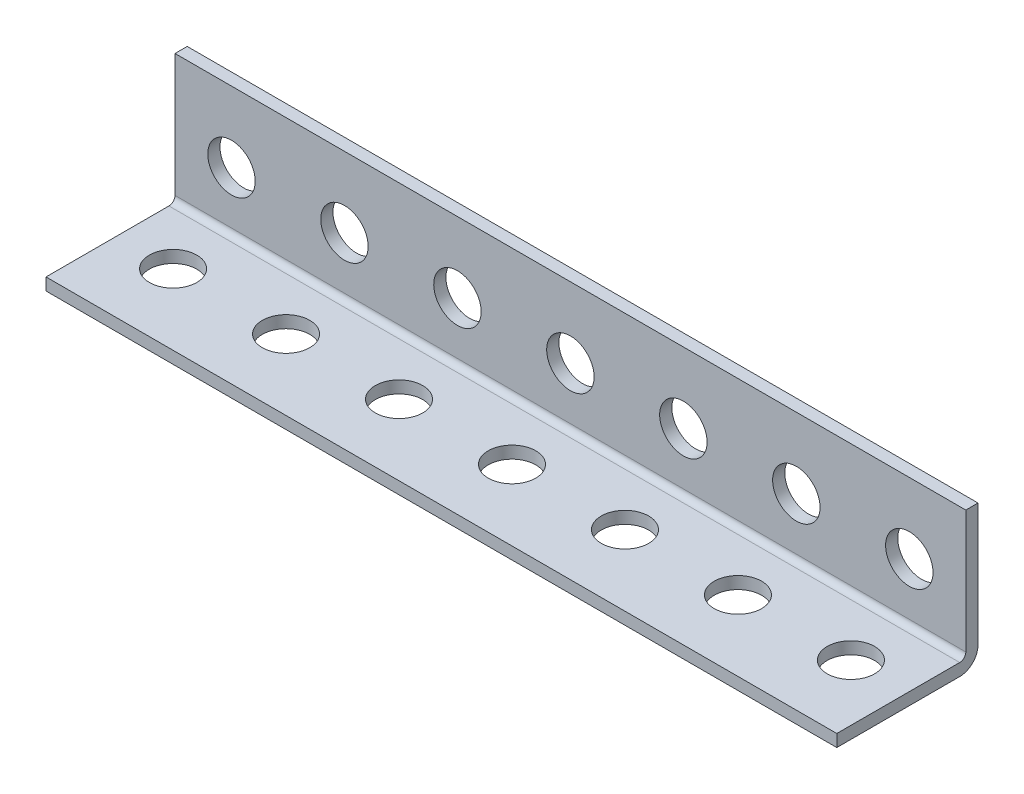
from build123d import *

# Parameters (mm, degrees)
BOSS_EXTRUDE1_DEPTH      = 609.6
BOSS_EXTRUDE1_DEPTH_BACK = 609.6
SKETCH5_R                = 5.334
CUT_EXTRUDE1_DEPTH       = 16.875
SKETCH6_R                = 5.334
CUT_EXTRUDE2_DEPTH       = 16.875
LPATTERN1_COUNT          = 48
LPATTERN1_PITCH          = 25.4
SKETCH7_W                = 635
SKETCH7_H                = 31.75
CUT_EXTRUDE3_DEPTH       = 70
SKETCH8_R                = 5.334
SKETCH8_W                = 25.4
SKETCH8_H                = 4.1148
CUT_EXTRUDE4_DEPTH       = 70
SKETCH9_R                = 5.334
SKETCH9_W                = 381
SKETCH9_H                = 4.1148
CUT_EXTRUDE5_DEPTH       = 70


with BuildPart() as part:
    # Sketch4 → Boss-Extrude1 (new body, two sides)
    with BuildSketch(Plane(origin=(0, 0, 0), x_dir=(0, 0, -1), z_dir=(1, 0, 0))) as boss_extrude1_sk:
        with BuildLine():
            Line((-15.875, -13.1318), (11.7602, -13.1318))
            ThreePointArc((11.7602, -13.1318), (12.730067661, -12.730067661), (13.1318, -11.7602))
            Line((13.1318, -11.7602), (13.1318, 15.875))
            Line((13.1318, 15.875), (15.875, 15.875))
            Line((15.875, 15.875), (15.875, -11.7602))
            ThreePointArc((15.875, -11.7602), (14.669802983, -14.669802983), (11.7602, -15.875))
            Line((11.7602, -15.875), (-15.875, -15.875))
            Line((-15.875, -15.875), (-15.875, -13.1318))
        make_face()
    extrude(amount=BOSS_EXTRUDE1_DEPTH)
    extrude(boss_extrude1_sk.sketch, amount=-BOSS_EXTRUDE1_DEPTH_BACK)

    # Sketch5 → Cut-Extrude1 (cut, through all)
    with BuildSketch(Plane.XY):
        with Locations((596.9, 0)):
            Circle(SKETCH5_R)
    cut_extrude1 = extrude(amount=-CUT_EXTRUDE1_DEPTH, mode=Mode.SUBTRACT)

    # Sketch6 → Cut-Extrude2 (cut, through all)
    with BuildSketch(Plane(origin=(0, 0, 0), x_dir=(1, 0, 0), z_dir=(0, 1, 0))):
        with Locations((596.9, 0)):
            Circle(SKETCH6_R)
    cut_extrude2 = extrude(amount=-CUT_EXTRUDE2_DEPTH, mode=Mode.SUBTRACT)

    # LPattern1: Cut-Extrude1, Cut-Extrude2 ×48
    with Locations(*[(-i * LPATTERN1_PITCH, 0, 0) for i in range(1, LPATTERN1_COUNT)]):
        add(cut_extrude1, mode=Mode.SUBTRACT)
        add(cut_extrude2, mode=Mode.SUBTRACT)

    # Sketch7 → Cut-Extrude3 (cut)
    with BuildSketch(Plane(origin=(0, 0, -15.875), x_dir=(-1, 0, 0), z_dir=(0, 0, -1))):
        with Locations((-292.1, 0)):
            Rectangle(SKETCH7_W, SKETCH7_H)
    extrude(amount=-CUT_EXTRUDE3_DEPTH, mode=Mode.SUBTRACT)

    # Sketch8 → Cut-Extrude4 (cut)
    with BuildSketch(Plane(origin=(0, 0, -15.875), x_dir=(-1, 0, 0), z_dir=(0, 0, -1))):
        Polygon((50.8, 15.875), (25.4, 15.875), (25.4, -11.7602), (50.8, -11.7602), (50.8, 0), align=None)
        with Locations((38.1, 0)):
            Circle(SKETCH8_R, mode=Mode.SUBTRACT)
        with Locations((38.1, -13.8176)):
            Rectangle(SKETCH8_W, SKETCH8_H)
    extrude(amount=-CUT_EXTRUDE4_DEPTH, mode=Mode.SUBTRACT)

    # Sketch9 → Cut-Extrude5 (cut)
    with BuildSketch(Plane(origin=(0, 0, -15.875), x_dir=(-1, 0, 0), z_dir=(0, 0, -1))):
        Polygon((431.8, 15.875), (50.8, 15.875), (50.8, -11.7602), (431.8, -11.7602), (431.8, 0), align=None)
        with Locations((63.5, 0)):
            Circle(SKETCH9_R, mode=Mode.SUBTRACT)
        with Locations((88.9, 0)):
            Circle(SKETCH9_R, mode=Mode.SUBTRACT)
        with Locations((114.3, 0)):
            Circle(SKETCH9_R, mode=Mode.SUBTRACT)
        with Locations((139.7, 0)):
            Circle(SKETCH9_R, mode=Mode.SUBTRACT)
        with Locations((165.1, 0)):
            Circle(SKETCH9_R, mode=Mode.SUBTRACT)
        with Locations((190.5, 0)):
            Circle(SKETCH9_R, mode=Mode.SUBTRACT)
        with Locations((215.9, 0)):
            Circle(SKETCH9_R, mode=Mode.SUBTRACT)
        with Locations((241.3, 0)):
            Circle(SKETCH9_R, mode=Mode.SUBTRACT)
        with Locations((266.7, 0)):
            Circle(SKETCH9_R, mode=Mode.SUBTRACT)
        with Locations((292.1, 0)):
            Circle(SKETCH9_R, mode=Mode.SUBTRACT)
        with Locations((317.5, 0)):
            Circle(SKETCH9_R, mode=Mode.SUBTRACT)
        with Locations((342.9, 0)):
            Circle(SKETCH9_R, mode=Mode.SUBTRACT)
        with Locations((368.3, 0)):
            Circle(SKETCH9_R, mode=Mode.SUBTRACT)
        with Locations((393.7, 0)):
            Circle(SKETCH9_R, mode=Mode.SUBTRACT)
        with Locations((419.1, 0)):
            Circle(SKETCH9_R, mode=Mode.SUBTRACT)
        with Locations((241.3, -13.8176)):
            Rectangle(SKETCH9_W, SKETCH9_H)
    extrude(amount=-CUT_EXTRUDE5_DEPTH, mode=Mode.SUBTRACT)


solid = part.part
